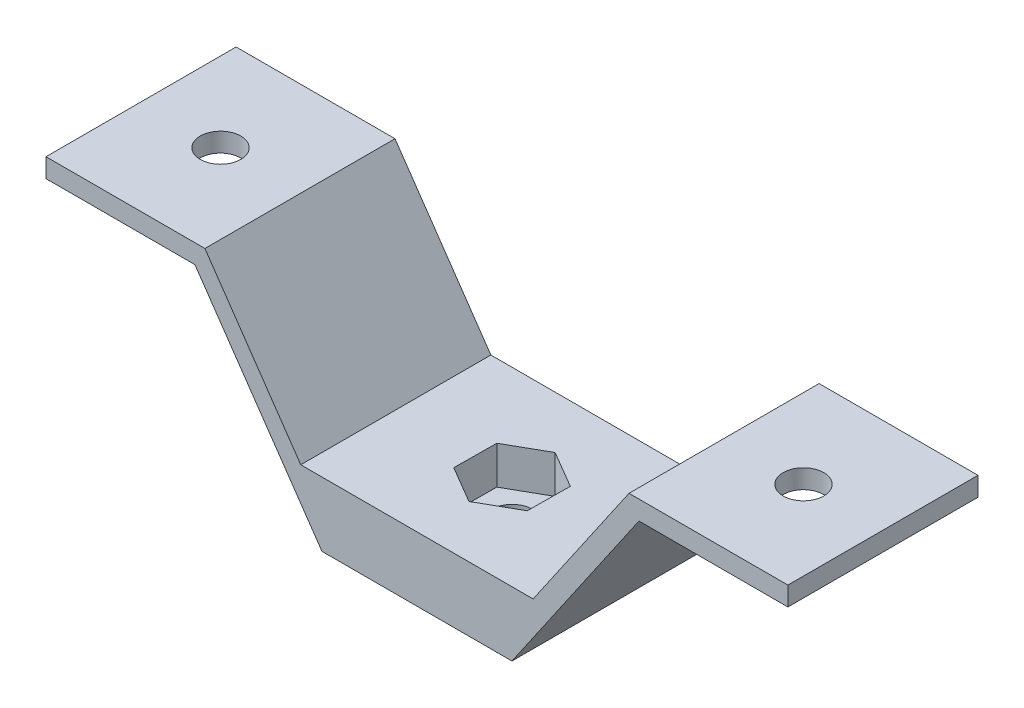
from build123d import *

# Parameters (mm, degrees)
BOSS_EXTRUDE1_DEPTH = 30
SKETCH2_R           = 3.2
CUT_EXTRUDE1_DEPTH  = 3
CUT_EXTRUDE2_REACH  = 12.16
SKETCH5_R           = 3.2
CUT_EXTRUDE3_DEPTH  = 6


with BuildPart() as part:
    # Sketch1 → Boss-Extrude1 (new body)
    with BuildSketch(Plane.XY):
        Polygon((0, 0), (14.990525772, 0), (35.038513576, 29.16), (58.53955614, 29.16), (58.53955614, 32.16), (33.46044386, 32.16), (18.335075832, 10.16), (0, 10.16), align=None)
    boss_extrude1 = extrude(amount=-BOSS_EXTRUDE1_DEPTH)

    # Mirror1: Boss-Extrude1 across plane
    add(boss_extrude1.mirror(Plane(origin=(0, 10.16, -30), x_dir=(0, 0, 1), z_dir=(-1, 0, 0))))

    # Sketch2 → Cut-Extrude1 (cut)
    with BuildSketch(Plane(origin=(0, 32.16, 0), x_dir=(1, 0, 0), z_dir=(0, 1, 0))):
        with Locations((-46, 15)):
            Circle(SKETCH2_R)
    cut_extrude1 = extrude(amount=-CUT_EXTRUDE1_DEPTH, mode=Mode.SUBTRACT)

    # Mirror2: Cut-Extrude1 across plane
    add(cut_extrude1.mirror(Plane(origin=(0, 0, 0), x_dir=(0, 0, 1), z_dir=(1, 0, 0))), mode=Mode.SUBTRACT)

    # Sketch5 → Cut-Extrude2 (cut, up to next)
    with BuildSketch(Plane(origin=(0, 10.16, 0), x_dir=(1, 0, 0), z_dir=(0, 1, 0)), mode=Mode.PRIVATE) as cut_extrude2_sk1:
        with Locations((0.006129123, 15)):
            Circle(SKETCH5_R)
    cut_extrude2_tool1 = extrude(cut_extrude2_sk1.sketch, amount=-CUT_EXTRUDE2_REACH, mode=Mode.PRIVATE) & part.part
    add(cut_extrude2_tool1.solids().sort_by_distance((0.006129, 10.16, -15))[0], mode=Mode.SUBTRACT)

    # Sketch6 → Cut-Extrude3 (cut)
    with BuildSketch(Plane(origin=(0, 10.16, 0), x_dir=(1, 0, 0), z_dir=(0, 1, 0))):
        Polygon((-5.809462538, 18.418212831), (-5.861925855, 11.672656299), (-0.046334193, 8.254443467), (5.821720785, 11.581787169), (5.874184102, 18.327343701), (0.05859244, 21.745556533), align=None)
    extrude(amount=-CUT_EXTRUDE3_DEPTH, mode=Mode.SUBTRACT)


solid = part.part
